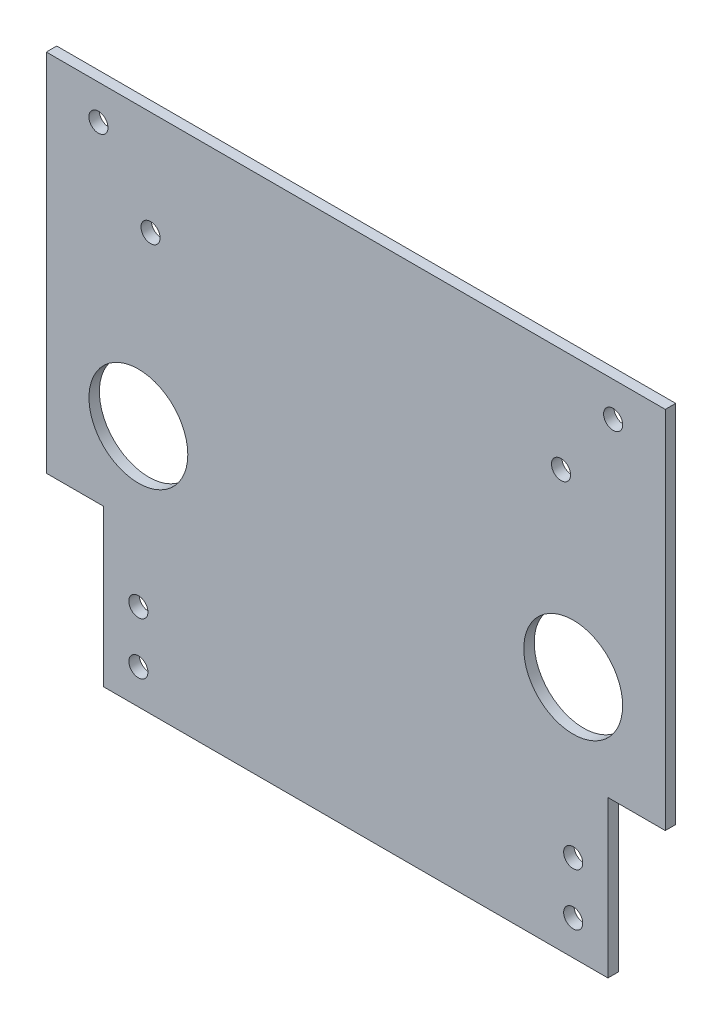
from build123d import *

# Parameters (mm, degrees)
SKETCH1_W           = 178.16
SKETCH1_H           = 150
BOSS_EXTRUDE1_DEPTH = 3
SKETCH2_R           = 14.225
SKETCH2_R_2         = 2.75
CUT_EXTRUDE1_DEPTH  = 4
SKETCH4_W           = 16.5
SKETCH4_H           = 45
CUT_EXTRUDE3_DEPTH  = 4
SKETCH5_R           = 2.75
CUT_EXTRUDE4_DEPTH  = 4


with BuildPart() as part:
    # Sketch1 → Boss-Extrude1 (new body)
    with BuildSketch(Plane.XY):
        with Locations((89.08, -75)):
            Rectangle(SKETCH1_W, SKETCH1_H)
    extrude(amount=BOSS_EXTRUDE1_DEPTH)

    # Sketch2 → Cut-Extrude1 (cut, through all)
    with BuildSketch(Plane.XY.offset(3)):
        with Locations((26.5, -80)):
            Circle(SKETCH2_R)
        with Locations((151.66, -80)):
            Circle(SKETCH2_R)
        with Locations((26.5, -140)):
            Circle(SKETCH2_R_2)
        with Locations((151.66, -140)):
            Circle(SKETCH2_R_2)
        with Locations((26.5, -125)):
            Circle(SKETCH2_R_2)
        with Locations((151.66, -125)):
            Circle(SKETCH2_R_2)
    extrude(amount=-CUT_EXTRUDE1_DEPTH, mode=Mode.SUBTRACT)

    # Sketch4 → Cut-Extrude3 (cut, through all)
    with BuildSketch(Plane.XY.offset(3)):
        with Locations((8.25, -127.5)):
            Rectangle(SKETCH4_W, SKETCH4_H)
        with Locations((169.91, -127.5)):
            Rectangle(SKETCH4_W, SKETCH4_H)
    extrude(amount=-CUT_EXTRUDE3_DEPTH, mode=Mode.SUBTRACT)

    # Sketch5 → Cut-Extrude4 (cut, through all)
    with BuildSketch(Plane.XY.offset(3)):
        with Locations((163.16, -10)):
            Circle(SKETCH5_R)
        with Locations((15, -10)):
            Circle(SKETCH5_R)
        with Locations((148.16, -30)):
            Circle(SKETCH5_R)
        with Locations((30, -30)):
            Circle(SKETCH5_R)
    extrude(amount=-CUT_EXTRUDE4_DEPTH, mode=Mode.SUBTRACT)


solid = part.part
